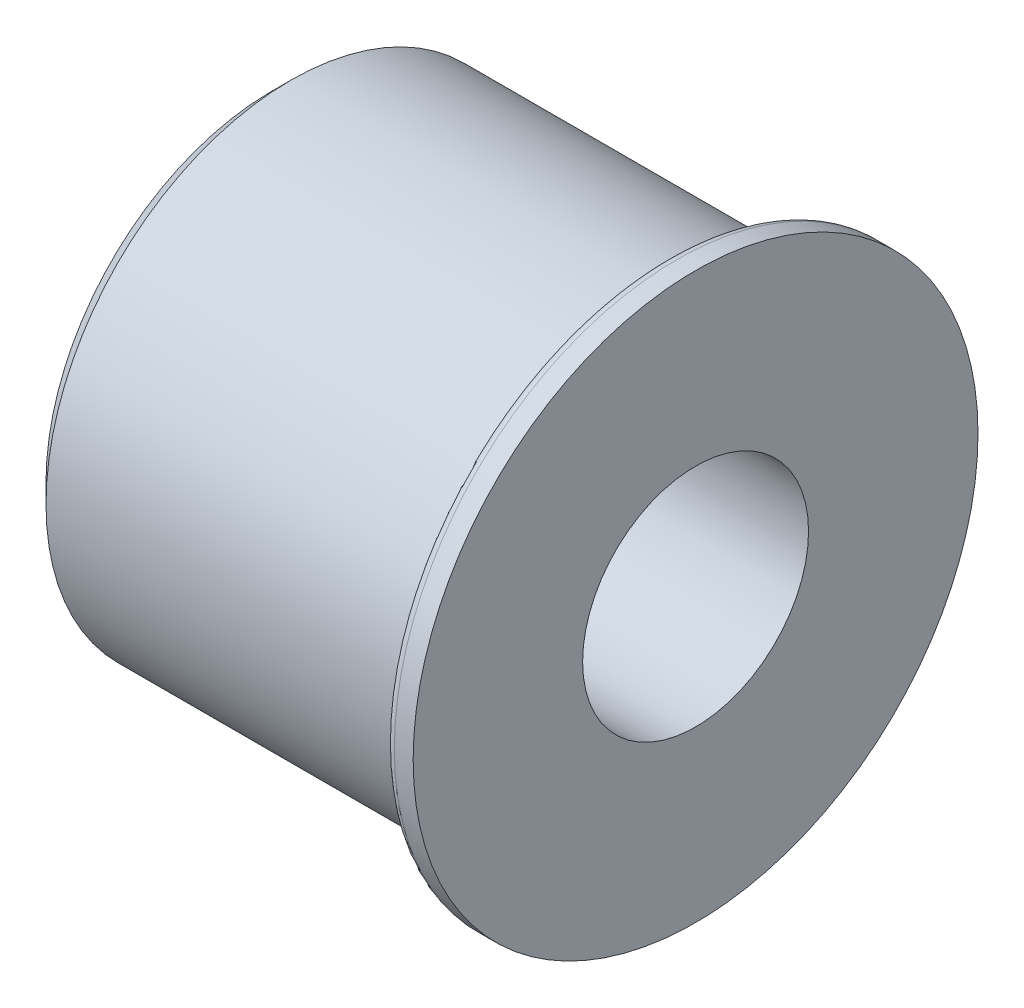
from build123d import *


with BuildPart() as part:
    # Esquisse1 → Révolution1 (revolve)
    with BuildSketch(Plane.XY, mode=Mode.PRIVATE) as r_volution1_sk:
        with BuildLine():
            Line((0, 6), (22.5, 6))
            Line((22.5, 6), (22.5, 15))
            Line((22.5, 15), (21.5, 15))
            ThreePointArc((21.5, 15), (21.146446609, 14.853553391), (21, 14.5))
            Line((21, 14.5), (21, 13))
            Line((21, 13), (1, 13))
            Line((1, 13), (0, 12))
            Line((0, 12), (0, 6))
        make_face()
    revolve(r_volution1_sk.sketch.rotate(Axis((0, 0, 0), (1, 0, 0)), 90), axis=Axis((0, 0, 0), (1, 0, 0)))  # turned: the seam where the file's is


solid = part.part
